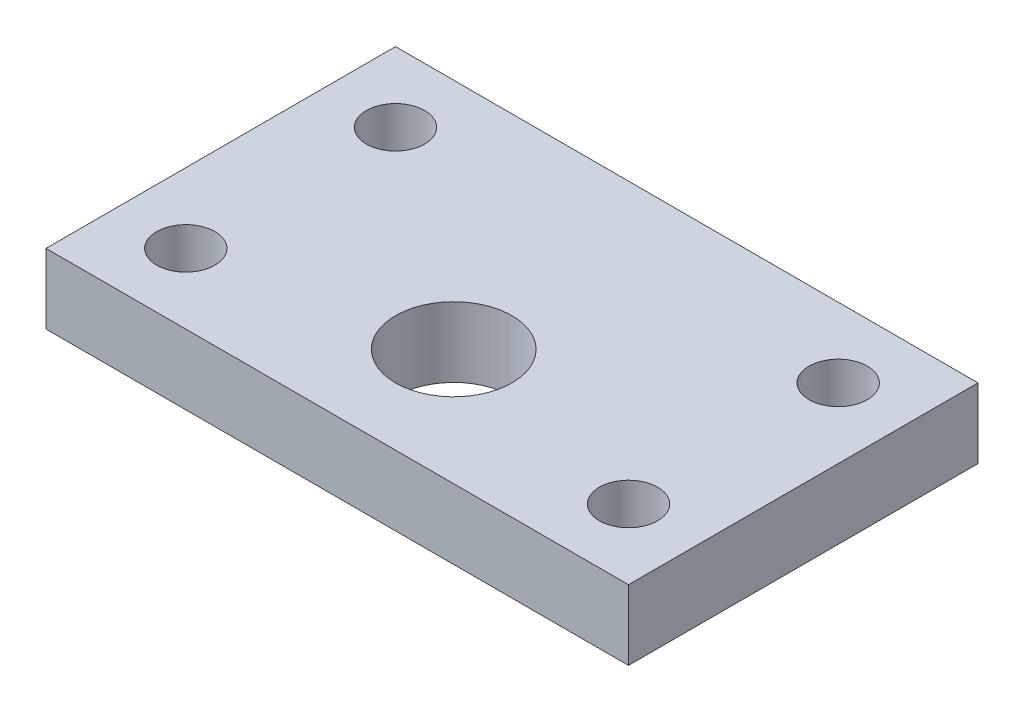
from build123d import *

# Parameters (mm, degrees)
SKETCH1_W           = 250
SKETCH1_H           = 150
SKETCH1_R           = 12.5
SKETCH1_R_2         = 25
BOSS_EXTRUDE1_DEPTH = 15


with BuildPart() as part:
    # Sketch1 → Boss-Extrude1 (new body, symmetric)
    with BuildSketch(Plane(origin=(0, 0, 0), x_dir=(1, 0, 0), z_dir=(0, 1, 0))):
        with Locations((0, 27)):
            Rectangle(SKETCH1_W, SKETCH1_H)
        with Locations((-95, 72)):
            Circle(SKETCH1_R, mode=Mode.SUBTRACT)
        with Locations((95, 72)):
            Circle(SKETCH1_R, mode=Mode.SUBTRACT)
        with Locations((95, -18)):
            Circle(SKETCH1_R, mode=Mode.SUBTRACT)
        with Locations((-95, -18)):
            Circle(SKETCH1_R, mode=Mode.SUBTRACT)
        with Locations((0, 2)):
            Circle(SKETCH1_R_2, mode=Mode.SUBTRACT)
    extrude(amount=BOSS_EXTRUDE1_DEPTH, both=True)


solid = part.part
